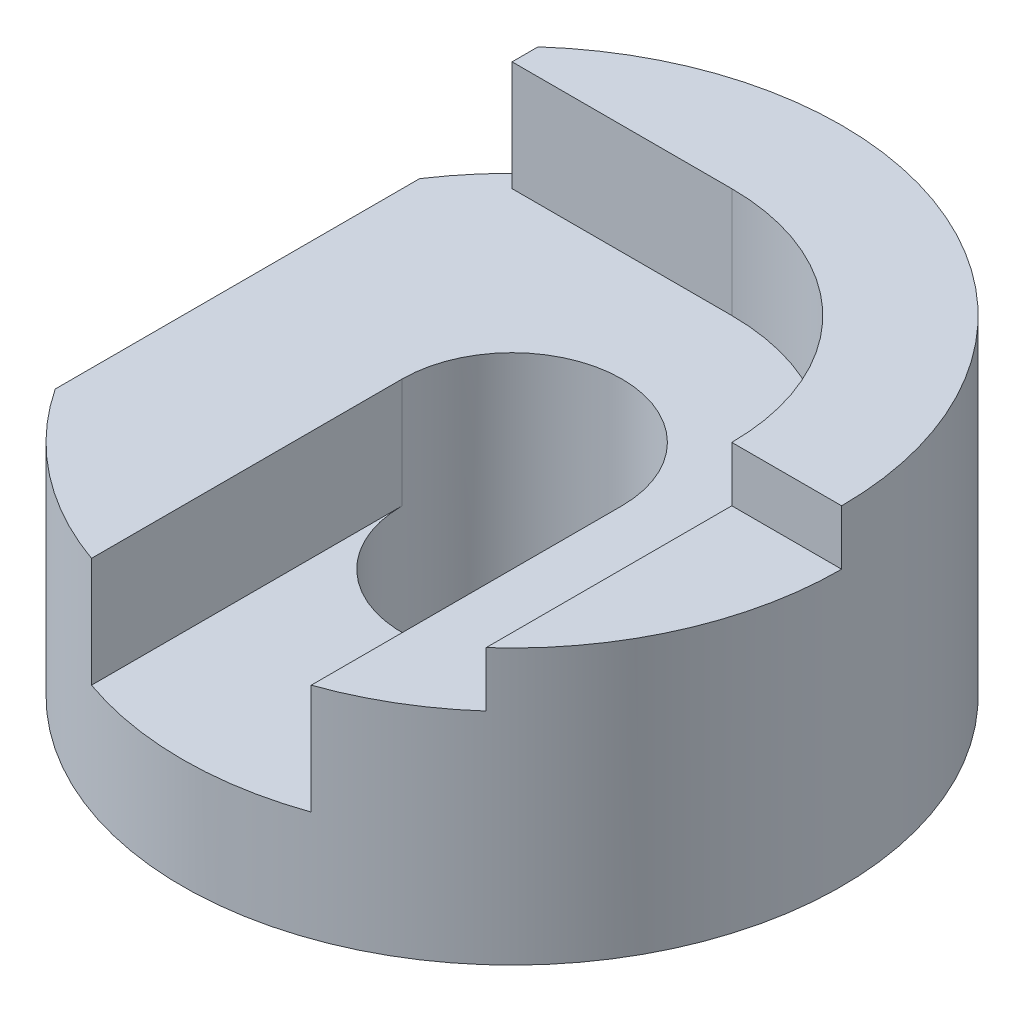
from build123d import *

# Parameters (mm, degrees)
SKETCH1_W           = 120
SKETCH1_H           = 60
BOSS_EXTRUDE1_DEPTH = 120
SKETCH2_W           = 10
SKETCH2_H           = 30
CUT_EXTRUDE1_DEPTH  = 120
SKETCH3_W           = 10
SKETCH3_H           = 20
CUT_EXTRUDE2_DEPTH  = 120
CUT_EXTRUDE3_DEPTH  = 120
SKETCH6_R           = 20
CUT_EXTRUDE4_DEPTH  = 120
CUT_EXTRUDE5_DEPTH  = 20
CUT_EXTRUDE8_DEPTH  = 20
SKETCH9_W           = 15
SKETCH9_H           = 10
CUT_EXTRUDE10_DEPTH = 20
SKETCH10_W          = 29.72135955
SKETCH10_H          = 10
CUT_EXTRUDE11_DEPTH = 20
CUT_EXTRUDE12_DEPTH = 20
SKETCH12_W          = 40
SKETCH12_H          = 20
CUT_EXTRUDE15_DEPTH = 20
SKETCH14_W          = 20
SKETCH14_H          = 40
BOSS_EXTRUDE6_DEPTH = 20


with BuildPart() as part:
    # Sketch1 → Boss-Extrude1 (new body)
    with BuildSketch(Plane.XY):
        with Locations((60, 30)):
            Rectangle(SKETCH1_W, SKETCH1_H)
    extrude(amount=BOSS_EXTRUDE1_DEPTH)

    # Sketch2 → Cut-Extrude1 (cut)
    with BuildSketch(Plane.XY.offset(120)):
        with Locations((5, 45)):
            Rectangle(SKETCH2_W, SKETCH2_H)
    extrude(amount=-CUT_EXTRUDE1_DEPTH, mode=Mode.SUBTRACT)

    # Sketch3 → Cut-Extrude2 (cut)
    with BuildSketch(Plane.XY.offset(120)):
        with Locations((15, 50)):
            Rectangle(SKETCH3_W, SKETCH3_H)
    extrude(amount=-CUT_EXTRUDE2_DEPTH, mode=Mode.SUBTRACT)

    # Sketch5 → Cut-Extrude3 (cut)
    with BuildSketch(Plane.XZ):
        with BuildLine():
            Line((60, 120), (0, 120))
            Line((0, 120), (0, 60))
            ThreePointArc((0, 60), (17.573593129, 102.426406871), (60, 120))
        make_face()
        with BuildLine():
            Line((120, 120), (60, 120))
            ThreePointArc((60, 120), (102.426406871, 102.426406871), (120, 60))
            Line((120, 60), (120, 120))
        make_face()
        with BuildLine():
            ThreePointArc((120, 60), (102.426406871, 17.573593129), (60, 0))
            Line((60, 0), (120, 0))
            Line((120, 0), (120, 60))
        make_face()
        with BuildLine():
            ThreePointArc((60, 0), (17.573593129, 17.573593129), (0, 60))
            Line((0, 60), (0, 0))
            Line((0, 0), (60, 0))
        make_face()
    extrude(amount=-CUT_EXTRUDE3_DEPTH, mode=Mode.SUBTRACT)

    # Sketch6 → Cut-Extrude4 (cut)
    with BuildSketch(Plane(origin=(0, 0, 0), x_dir=(-1, 0, 0), z_dir=(0, -1, 0))):
        with Locations((-60, -60)):
            Circle(SKETCH6_R)
    extrude(amount=-CUT_EXTRUDE4_DEPTH, mode=Mode.SUBTRACT)

    # Sketch7 → Cut-Extrude5 (cut)
    with BuildSketch(Plane(origin=(0, 60, 0), x_dir=(1, 0, 0), z_dir=(0, 1, 0))):
        with BuildLine():
            Line((40, -60), (40, -116.568542495))
            ThreePointArc((40, -116.568542495), (60, -120), (80, -116.568542495))
            Line((80, -116.568542495), (80, -60))
            ThreePointArc((80, -60), (60, -80), (40, -60))
        make_face()
    extrude(amount=-CUT_EXTRUDE5_DEPTH, mode=Mode.SUBTRACT)

    # Sketch8 → Cut-Extrude8 (cut)
    with BuildSketch(Plane(origin=(0, 60, 0), x_dir=(1, 0, 0), z_dir=(0, 1, 0))):
        with BuildLine():
            ThreePointArc((100, -60), (88.284271247, -31.715728753), (60, -20))
            Line((60, -20), (20, -20))
            Line((20, -20), (20, -104.72135955))
            ThreePointArc((20, -104.72135955), (29.420776074, -111.622776602), (40, -116.568542495))
            Line((40, -116.568542495), (40, -60))
            ThreePointArc((40, -60), (60, -40), (80, -60))
            Line((80, -60), (80, -116.568542495))
            ThreePointArc((80, -116.568542495), (90.579223926, -111.622776602), (100, -104.72135955))
            Line((100, -104.72135955), (100, -60))
        make_face()
    extrude(amount=-CUT_EXTRUDE8_DEPTH, mode=Mode.SUBTRACT)

    # Sketch9 → Cut-Extrude10 (cut)
    with BuildSketch(Plane.ZY.offset(-100)):
        with Locations((97.22135955, 55)):
            Rectangle(SKETCH9_W, SKETCH9_H)
    extrude(amount=-CUT_EXTRUDE10_DEPTH, mode=Mode.SUBTRACT)

    # Sketch10 → Cut-Extrude11 (cut)
    with BuildSketch(Plane.ZY.offset(-100)):
        with Locations((74.860679775, 55)):
            Rectangle(SKETCH10_W, SKETCH10_H)
    extrude(amount=-CUT_EXTRUDE11_DEPTH, mode=Mode.SUBTRACT)

    # Sketch11 → Cut-Extrude12 (cut)
    with BuildSketch(Plane(origin=(0, 40, 0), x_dir=(1, 0, 0), z_dir=(0, 1, 0))):
        with BuildLine():
            Line((40, -60), (40, -116.568542495))
            ThreePointArc((40, -116.568542495), (60, -120), (80, -116.568542495))
            Line((80, -116.568542495), (80, -60))
            ThreePointArc((80, -60), (60, -80), (40, -60))
        make_face()
    extrude(amount=-CUT_EXTRUDE12_DEPTH, mode=Mode.SUBTRACT)

    # Sketch12 → Cut-Extrude15 (cut)
    with BuildSketch(Plane(origin=(40, 0, 0), x_dir=(0, 0, -1), z_dir=(1, 0, 0))):
        with Locations((-60, 30)):
            Rectangle(SKETCH12_W, SKETCH12_H)
    extrude(amount=-CUT_EXTRUDE15_DEPTH, mode=Mode.SUBTRACT)

    # Sketch14 → Boss-Extrude6 (add)
    with BuildSketch(Plane(origin=(0, 40, 0), x_dir=(1, 0, 0), z_dir=(0, 1, 0))):
        with Locations((30, -60)):
            Rectangle(SKETCH14_W, SKETCH14_H)
    extrude(amount=-BOSS_EXTRUDE6_DEPTH)


solid = part.part
